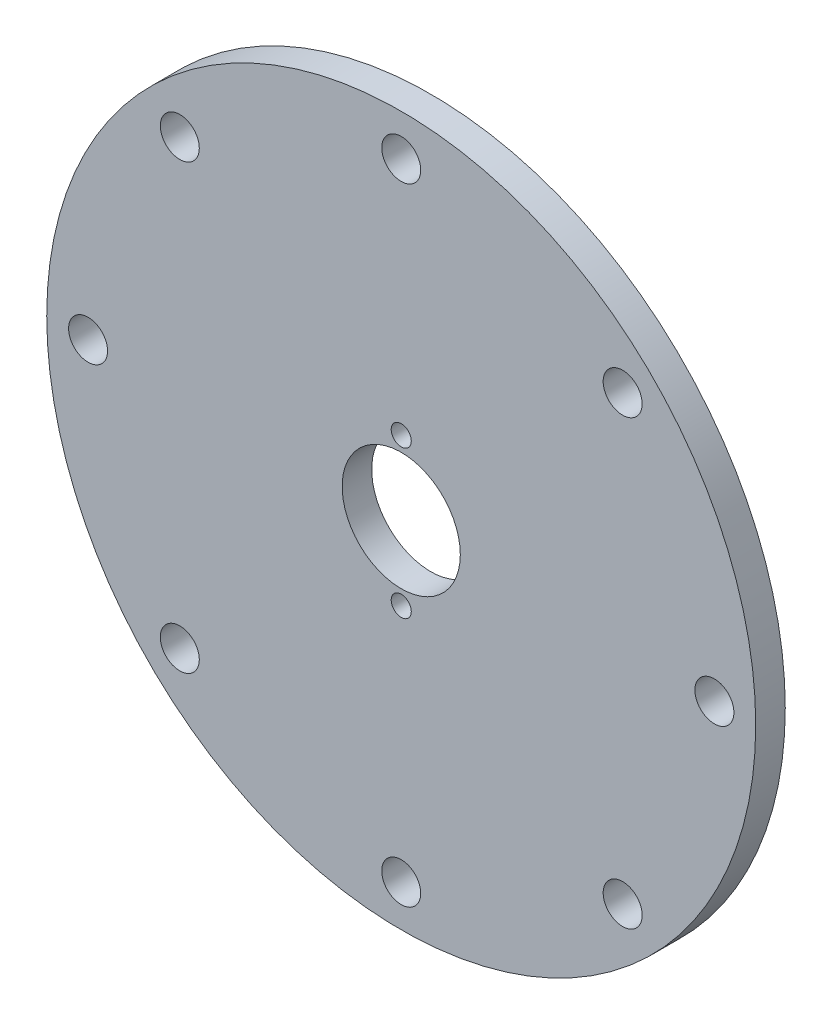
from build123d import *

# Parameters (mm, degrees)
SKETCH1_R               = 60
BOSS_EXTRUDE1_DEPTH     = 5
SKETCH7_R               = 10
CUT_EXTRUDE1_DEPTH      = 1
CUT_EXTRUDE1_DEPTH_BACK = 6
M3_CLEARANCE_HOLE1_D    = 3.4
M6_CLEARANCE_HOLE1_D    = 6.6


with BuildPart() as part:
    # Sketch1 → Boss-Extrude1 (new body)
    with BuildSketch(Plane.XY):
        Circle(SKETCH1_R)
    extrude(amount=BOSS_EXTRUDE1_DEPTH)

    # Sketch7 → Cut-Extrude1 (cut, two sides)
    with BuildSketch(Plane.XY.offset(5)) as cut_extrude1_sk:
        Circle(SKETCH7_R)
    extrude(amount=CUT_EXTRUDE1_DEPTH, mode=Mode.SUBTRACT)
    extrude(cut_extrude1_sk.sketch, amount=-CUT_EXTRUDE1_DEPTH_BACK, mode=Mode.SUBTRACT)

    # M3 Clearance Hole1 (through all)
    with Locations(Plane.XY.offset(5)):
        with Locations((0, 12.5), (0, -12.5)):
            Hole(M3_CLEARANCE_HOLE1_D / 2)

    # M6 Clearance Hole1 (through all)
    with Locations(Plane.XY.offset(5)):
        with Locations((-37.476659403, 37.476659403), (0, 53), (37.476659403, 37.476659403), (53, 0), (37.476659403, -37.476659403), (0, -53), (-37.476659403, -37.476659403), (-53, 0)):
            Hole(M6_CLEARANCE_HOLE1_D / 2)


solid = part.part
